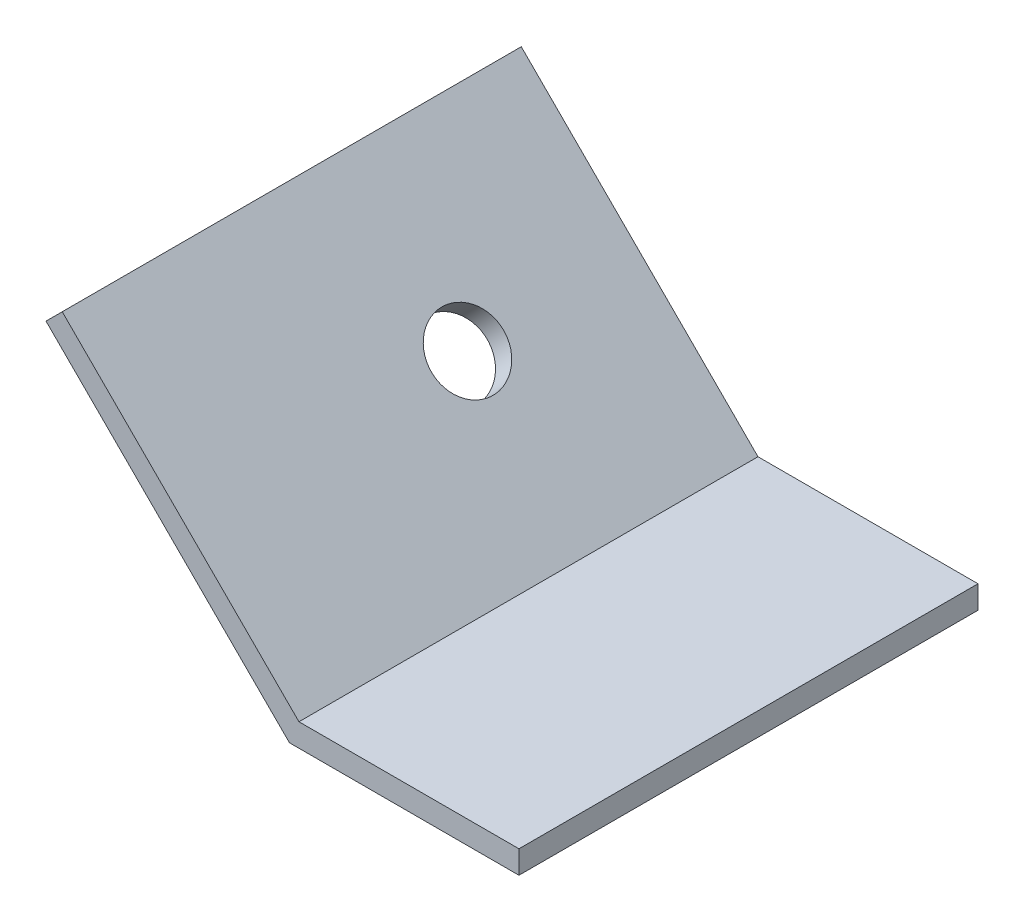
from build123d import *

# Parameters (mm, degrees)
BASE_DEPTH      = 50.8
AXLE_HOLE_REACH = 23.59
SKETCH2_R       = 4


with BuildPart() as part:
    # Sketch1 → base (new body)
    with BuildSketch(Plane.XY):
        Polygon((-26.940768363, 26.940768363), (0, 0), (25.4, 0), (25.4, 2.54), (1.052102448, 2.54), (-25.144717139, 28.736819587), align=None)
    extrude(amount=BASE_DEPTH)

    # Sketch2 → axle hole (cut, up to next)
    with BuildSketch(Plane(origin=(1.796051224, 1.796051224, 0), x_dir=(0, 0, -1), z_dir=(0.707106781, 0.707106781, 0)), mode=Mode.PRIVATE) as axle_hole_sk1:
        with Locations((-19.05, 19.576051224)):
            Circle(SKETCH2_R)
    axle_hole_tool1 = extrude(axle_hole_sk1.sketch, amount=-AXLE_HOLE_REACH, mode=Mode.PRIVATE) & part.part
    add(axle_hole_tool1.solids().sort_by_distance((-12.046307, 15.63841, 19.05))[0], mode=Mode.SUBTRACT)


solid = part.part
